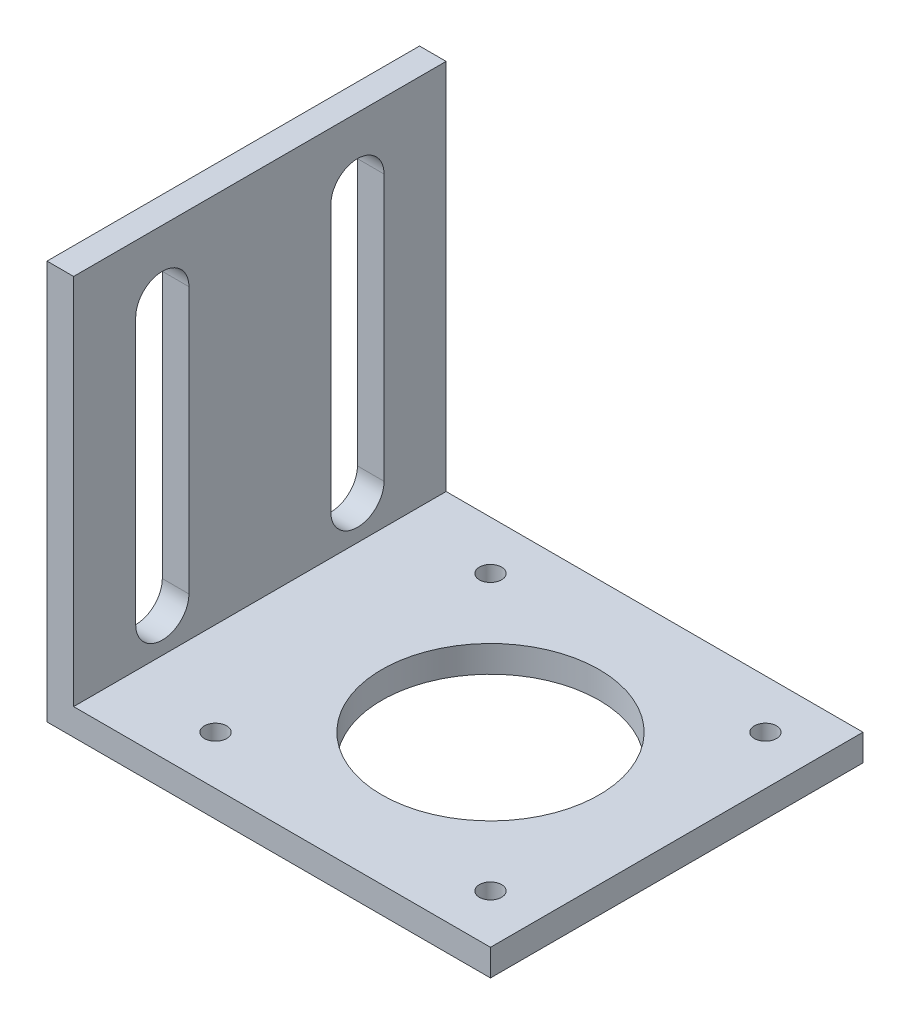
from build123d import *

# Parameters (mm, degrees)
SKETCH1_W           = 50
SKETCH1_H           = 42
BOSS_EXTRUDE1_DEPTH = 3
SKETCH2_W           = 3
SKETCH2_H           = 42
BOSS_EXTRUDE2_DEPTH = 42
CUT_EXTRUDE2_DEPTH  = 10
SKETCH5_R           = 12.25
SKETCH5_R_2         = 1.25
CUT_EXTRUDE3_DEPTH  = 10


with BuildPart() as part:
    # Sketch1 → Boss-Extrude1 (new body)
    with BuildSketch(Plane(origin=(0, 0, 0), x_dir=(1, 0, 0), z_dir=(0, 1, 0))):
        Rectangle(SKETCH1_W, SKETCH1_H)
    extrude(amount=BOSS_EXTRUDE1_DEPTH)

    # Sketch2 → Boss-Extrude2 (add)
    with BuildSketch(Plane(origin=(0, 3, 0), x_dir=(1, 0, 0), z_dir=(0, 1, 0))):
        with Locations((-23.5, 0)):
            Rectangle(SKETCH2_W, SKETCH2_H)
    extrude(amount=BOSS_EXTRUDE2_DEPTH)

    # Sketch4 → Cut-Extrude2 (cut)
    with BuildSketch(Plane.ZY.offset(25)):
        with BuildLine():
            ThreePointArc((-8, 7.5), (-11, 10.5), (-14, 7.5))
            Line((-14, 7.5), (-8, 7.5))
        make_face()
        with BuildLine():
            Line((-8, 7.5), (-14, 7.5))
            ThreePointArc((-14, 7.5), (-11, 4.5), (-8, 7.5))
        make_face()
        with BuildLine():
            Line((-14, 37.5), (-14, 7.5))
            ThreePointArc((-14, 7.5), (-11, 10.5), (-8, 7.5))
            Line((-8, 7.5), (-8, 37.5))
            ThreePointArc((-8, 37.5), (-11, 34.5), (-14, 37.5))
        make_face()
        with BuildLine():
            ThreePointArc((-8, 37.5), (-11, 40.5), (-14, 37.5))
            Line((-14, 37.5), (-8, 37.5))
        make_face()
        with BuildLine():
            Line((-8, 37.5), (-14, 37.5))
            ThreePointArc((-14, 37.5), (-11, 34.5), (-8, 37.5))
        make_face()
        with BuildLine():
            Line((8, 37.5), (8, 7.5))
            ThreePointArc((8, 7.5), (11, 10.5), (14, 7.5))
            Line((14, 7.5), (14, 37.5))
            ThreePointArc((14, 37.5), (11, 34.5), (8, 37.5))
        make_face()
        with BuildLine():
            ThreePointArc((14, 37.5), (11, 40.5), (8, 37.5))
            Line((8, 37.5), (14, 37.5))
        make_face()
        with BuildLine():
            Line((14, 37.5), (8, 37.5))
            ThreePointArc((8, 37.5), (11, 34.5), (14, 37.5))
        make_face()
        with BuildLine():
            ThreePointArc((14, 7.5), (11, 10.5), (8, 7.5))
            Line((8, 7.5), (14, 7.5))
        make_face()
        with BuildLine():
            Line((14, 7.5), (8, 7.5))
            ThreePointArc((8, 7.5), (11, 4.5), (14, 7.5))
        make_face()
    extrude(amount=-CUT_EXTRUDE2_DEPTH, mode=Mode.SUBTRACT)

    # Sketch5 → Cut-Extrude3 (cut)
    with BuildSketch(Plane(origin=(0, 3, 0), x_dir=(1, 0, 0), z_dir=(0, 1, 0))):
        with Locations((4, 0)):
            Circle(SKETCH5_R)
        with Locations((-11.5, -15.5)):
            Circle(SKETCH5_R_2)
        with Locations((19.5, -15.5)):
            Circle(SKETCH5_R_2)
        with Locations((19.5, 15.5)):
            Circle(SKETCH5_R_2)
        with Locations((-11.5, 15.5)):
            Circle(SKETCH5_R_2)
    extrude(amount=-CUT_EXTRUDE3_DEPTH, mode=Mode.SUBTRACT)


solid = part.part
